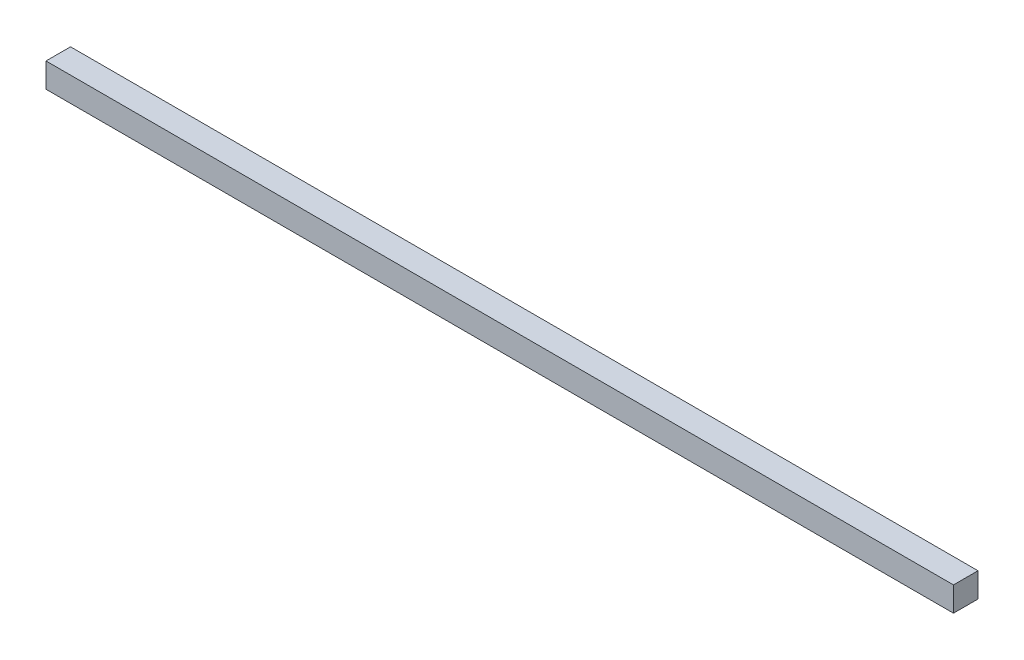
from build123d import *

# Parameters (mm, degrees)
SKETCH1_W           = 25.4
SKETCH1_H           = 25.4
BOSS_EXTRUDE2_DEPTH = 939.8


with BuildPart() as part:
    # Sketch1 → Boss-Extrude2 (new body)
    with BuildSketch(Plane(origin=(0, 0, 0), x_dir=(0, 0, -1), z_dir=(1, 0, 0))):
        with Locations((12.7, 12.7)):
            Rectangle(SKETCH1_W, SKETCH1_H)
    extrude(amount=BOSS_EXTRUDE2_DEPTH)


solid = part.part
